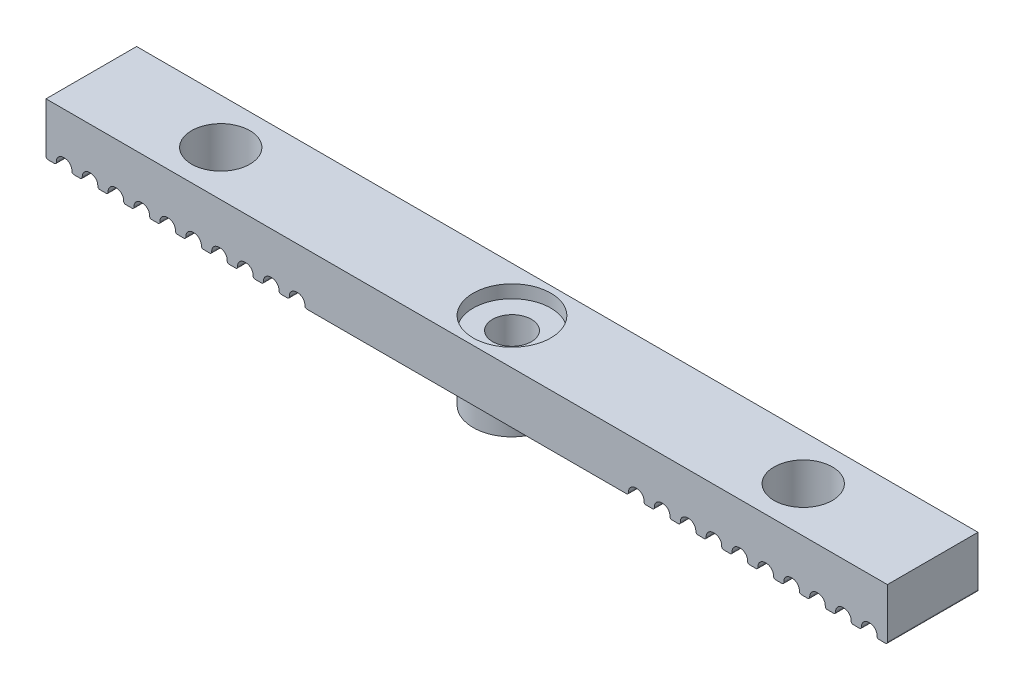
from build123d import *

# Parameters (mm, degrees)
SKETCH1_W           = 65
SKETCH1_H           = 7
BOSS_EXTRUDE1_DEPTH = 4
CUT_EXTRUDE1_REACH  = 34.932
SKETCH2_R           = 1.5
SKETCH3_R           = 3
CUT_EXTRUDE2_DEPTH  = 1
SKETCH4_R           = 3
SKETCH4_R_2         = 1.5
BOSS_EXTRUDE2_DEPTH = 2
SKETCH5_W           = 1.2
SKETCH5_H           = 0.75
CUT_EXTRUDE3_DEPTH  = 34.485071301
FILLET1_R           = 0.15
FILLET2_R           = 0.555
SKETCH6_R           = 2.25
CUT_EXTRUDE4_DEPTH  = 34.234018716


with BuildPart() as part:
    # Sketch1 → Boss-Extrude1 (new body)
    with BuildSketch(Plane(origin=(0, 0, 0), x_dir=(1, 0, 0), z_dir=(0, 1, 0))):
        Rectangle(SKETCH1_W, SKETCH1_H)
    extrude(amount=BOSS_EXTRUDE1_DEPTH)

    # Sketch2 → Cut-Extrude1 (cut, up to next)
    with BuildSketch(Plane(origin=(0, 4, 0), x_dir=(1, 0, 0), z_dir=(0, 1, 0)), mode=Mode.PRIVATE) as cut_extrude1_sk1:
        with Locations(Location((0, 0, 0), (0, 0, 270))):
            Circle(SKETCH2_R)
    cut_extrude1_tool1 = extrude(cut_extrude1_sk1.sketch, amount=-CUT_EXTRUDE1_REACH, mode=Mode.PRIVATE) & part.part
    add(cut_extrude1_tool1.solids().sort_by_distance((0, 4, 0))[0], mode=Mode.SUBTRACT)

    # Sketch3 → Cut-Extrude2 (cut)
    with BuildSketch(Plane(origin=(0, 4, 0), x_dir=(1, 0, 0), z_dir=(0, 1, 0))):
        with Locations(Location((0, 0, 0), (0, 0, 270))):
            Circle(SKETCH3_R)
    extrude(amount=-CUT_EXTRUDE2_DEPTH, mode=Mode.SUBTRACT)

    # Sketch4 → Boss-Extrude2 (add)
    with BuildSketch(Plane(origin=(0, 0, 0), x_dir=(-1, 0, 0), z_dir=(0, -1, 0))):
        with Locations(Location((0, 0, 0), (0, 0, 270))):
            Circle(SKETCH4_R)
        with Locations(Location((0, 0, 0), (0, 0, 270))):
            Circle(SKETCH4_R_2, mode=Mode.SUBTRACT)
    extrude(amount=BOSS_EXTRUDE2_DEPTH)

    # Sketch5 → Cut-Extrude3 (cut, through all)
    with BuildSketch(Plane(origin=(0, 0, -3.5), x_dir=(-1, 0, 0), z_dir=(0, 0, -1))):
        with Locations((31.1, 0.375)):
            Rectangle(SKETCH5_W, SKETCH5_H)
        with Locations((29.1, 0.375)):
            Rectangle(SKETCH5_W, SKETCH5_H)
        with Locations((27.1, 0.375)):
            Rectangle(SKETCH5_W, SKETCH5_H)
        with Locations((25.1, 0.375)):
            Rectangle(SKETCH5_W, SKETCH5_H)
        with Locations((23.1, 0.375)):
            Rectangle(SKETCH5_W, SKETCH5_H)
        with Locations((21.1, 0.375)):
            Rectangle(SKETCH5_W, SKETCH5_H)
        with Locations((19.1, 0.375)):
            Rectangle(SKETCH5_W, SKETCH5_H)
        with Locations((17.1, 0.375)):
            Rectangle(SKETCH5_W, SKETCH5_H)
        with Locations((15.1, 0.375)):
            Rectangle(SKETCH5_W, SKETCH5_H)
        with Locations((13.1, 0.375)):
            Rectangle(SKETCH5_W, SKETCH5_H)
        with Locations((-31.1, 0.375)):
            Rectangle(SKETCH5_W, SKETCH5_H)
        with Locations((-29.1, 0.375)):
            Rectangle(SKETCH5_W, SKETCH5_H)
        with Locations((-27.1, 0.375)):
            Rectangle(SKETCH5_W, SKETCH5_H)
        with Locations((-25.1, 0.375)):
            Rectangle(SKETCH5_W, SKETCH5_H)
        with Locations((-23.1, 0.375)):
            Rectangle(SKETCH5_W, SKETCH5_H)
        with Locations((-21.1, 0.375)):
            Rectangle(SKETCH5_W, SKETCH5_H)
        with Locations((-19.1, 0.375)):
            Rectangle(SKETCH5_W, SKETCH5_H)
        with Locations((-17.1, 0.375)):
            Rectangle(SKETCH5_W, SKETCH5_H)
        with Locations((-15.1, 0.375)):
            Rectangle(SKETCH5_W, SKETCH5_H)
        with Locations((-13.1, 0.375)):
            Rectangle(SKETCH5_W, SKETCH5_H)
    extrude(amount=-CUT_EXTRUDE3_DEPTH, mode=Mode.SUBTRACT)

    # Fillet1
    fillet1_edges = [part.edges().sort_by_distance(p)[0] for p in [
        (-30.5, 0, 0),
        (-31.7, 0, 0),
        (12.5, 0, 0),
        (13.7, 0, 0),
        (14.5, 0, 0),
        (15.7, 0, 0),
        (16.5, 0, 0),
        (17.7, 0, 0),
        (26.5, 0, 0),
        (27.7, 0, 0),
        (28.5, 0, 0),
        (29.7, 0, 0),
        (30.5, 0, 0),
        (31.7, 0, 0),
        (-12.5, 0, 0),
        (-13.7, 0, 0),
        (24.5, 0, 0),
        (25.7, 0, 0),
        (22.5, 0, 0),
        (23.7, 0, 0),
        (20.5, 0, 0),
        (21.7, 0, 0),
        (18.5, 0, 0),
        (19.7, 0, 0),
        (-14.5, 0, 0),
        (-15.7, 0, 0),
        (-16.5, 0, 0),
        (-17.7, 0, 0),
        (-18.5, 0, 0),
        (-19.7, 0, 0),
        (-20.5, 0, 0),
        (-21.7, 0, 0),
        (-22.5, 0, 0),
        (-23.7, 0, 0),
        (-24.5, 0, 0),
        (-25.7, 0, 0),
        (-26.5, 0, 0),
        (-27.7, 0, 0),
        (-28.5, 0, 0),
        (-29.7, 0, 0),
        (-32.5, 0, 0),
        (32.5, 0, 0),
    ]]
    fillet(fillet1_edges, radius=FILLET1_R)

    # Fillet2
    fillet2_edges = [part.edges().sort_by_distance(p)[0] for p in [
        (-30.5, 0.75, 0),
        (-31.7, 0.75, 0),
        (13.7, 0.75, 0),
        (12.5, 0.75, 0),
        (14.5, 0.75, 0),
        (15.7, 0.75, 0),
        (16.5, 0.75, 0),
        (17.7, 0.75, 0),
        (26.5, 0.75, 0),
        (27.7, 0.75, 0),
        (28.5, 0.75, 0),
        (29.7, 0.75, 0),
        (30.5, 0.75, 0),
        (31.7, 0.75, 0),
        (-12.5, 0.75, 0),
        (-13.7, 0.75, 0),
        (24.5, 0.75, 0),
        (25.7, 0.75, 0),
        (22.5, 0.75, 0),
        (23.7, 0.75, 0),
        (20.5, 0.75, 0),
        (21.7, 0.75, 0),
        (18.5, 0.75, 0),
        (19.7, 0.75, 0),
        (-14.5, 0.75, 0),
        (-15.7, 0.75, 0),
        (-16.5, 0.75, 0),
        (-17.7, 0.75, 0),
        (-18.5, 0.75, 0),
        (-19.7, 0.75, 0),
        (-20.5, 0.75, 0),
        (-21.7, 0.75, 0),
        (-22.5, 0.75, 0),
        (-23.7, 0.75, 0),
        (-24.5, 0.75, 0),
        (-25.7, 0.75, 0),
        (-26.5, 0.75, 0),
        (-27.7, 0.75, 0),
        (-28.5, 0.75, 0),
        (-29.7, 0.75, 0),
    ]]
    fillet(fillet2_edges, radius=FILLET2_R)

    # Sketch6 → Cut-Extrude4 (cut, through all)
    with BuildSketch(Plane(origin=(0, 4, 0), x_dir=(1, 0, 0), z_dir=(0, 1, 0))):
        with Locations(Location((-22.5, 0, 0), (0, 0, 270))):
            Circle(SKETCH6_R)
        with Locations(Location((22.5, 0, 0), (0, 0, 270))):
            Circle(SKETCH6_R)
    extrude(amount=-CUT_EXTRUDE4_DEPTH, mode=Mode.SUBTRACT)


solid = part.part
